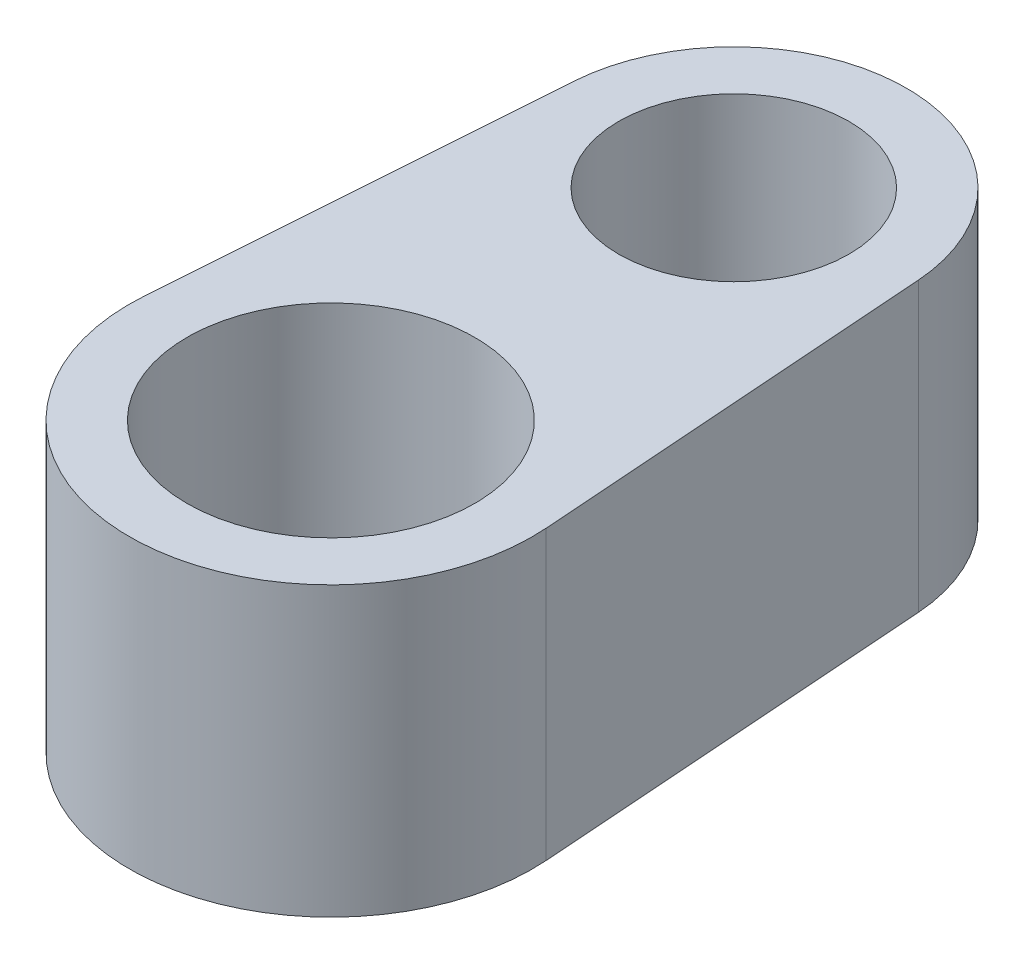
from build123d import *

# Parameters (mm, degrees)
SKETCH1_R           = 2.54
SKETCH1_R_2         = 3.175
BOSS_EXTRUDE1_DEPTH = 6.35


with BuildPart() as part:
    # Sketch1 → Boss-Extrude1 (new body)
    with BuildSketch(Plane(origin=(0, 0, 0), x_dir=(1, 0, 0), z_dir=(0, 1, 0))):
        with BuildLine():
            Line((4.433646214, 0.3175), (3.800268183, 9.162142857))
            ThreePointArc((3.800268183, 9.162142857), (0, 12.7), (-3.800268183, 9.162142857))
            Line((-3.800268183, 9.162142857), (-4.433646214, 0.3175))
            ThreePointArc((-4.433646214, 0.3175), (0, -4.445), (4.433646214, 0.3175))
        make_face()
        with Locations((0, 8.89)):
            Circle(SKETCH1_R, mode=Mode.SUBTRACT)
        Circle(SKETCH1_R_2, mode=Mode.SUBTRACT)
    extrude(amount=BOSS_EXTRUDE1_DEPTH)


solid = part.part
